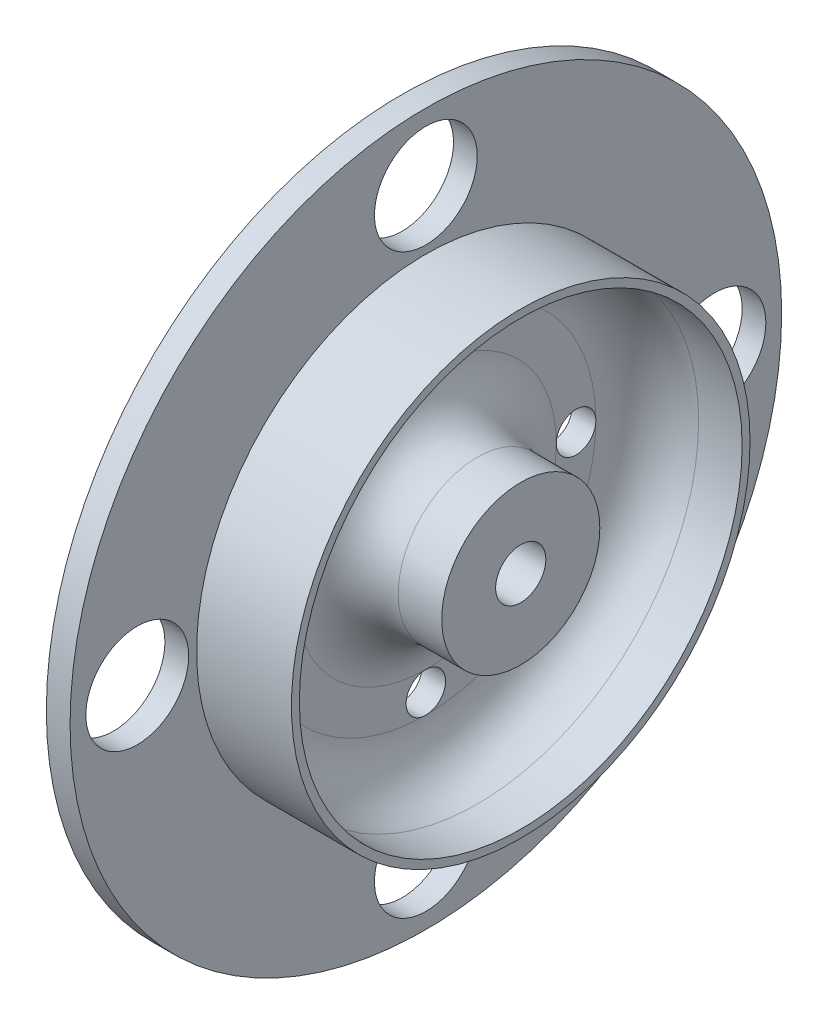
from build123d import *

# Parameters (mm, degrees)
SPROCKET_R                   = 45
ESTRUSIONE_ESTRUSIONE2_DEPTH = 3
SCHIZZO4_R                   = 10
ESTRUSIONE_ESTRUSIONE4_DEPTH = 12
SCHIZZO5_R                   = 29
SCHIZZO5_R_2                 = 28
ESTRUSIONE_ESTRUSIONE5_DEPTH = 12
SCHIZZO6_R                   = 3.175
TAGLIO_ESTRUSIONE1_DEPTH     = 15
RACCORDO1_R                  = 6.5
SCHIZZO7_R                   = 6.5
SCHIZZO7_R_2                 = 2.5
TAGLIO_ESTRUSIONE2_DEPTH     = 4
SCALE1_SCALE                 = 0.888888889


with BuildPart() as part:
    # Sprocket → Estrusione-Estrusione2 (new body)
    with BuildSketch(Plane(origin=(0, 0, 0), x_dir=(0, 0, -1), z_dir=(1, 0, 0))):
        Circle(SPROCKET_R)
    extrude(amount=ESTRUSIONE_ESTRUSIONE2_DEPTH)

    # Schizzo4 → Estrusione-Estrusione4 (add)
    with BuildSketch(Plane(origin=(3, 0, 0), x_dir=(0, 0, -1), z_dir=(1, 0, 0))):
        Circle(SCHIZZO4_R)
    extrude(amount=ESTRUSIONE_ESTRUSIONE4_DEPTH)

    # Schizzo5 → Estrusione-Estrusione5 (add)
    with BuildSketch(Plane(origin=(3, 0, 0), x_dir=(0, 0, -1), z_dir=(1, 0, 0))):
        Circle(SCHIZZO5_R)
        Circle(SCHIZZO5_R_2, mode=Mode.SUBTRACT)
    extrude(amount=ESTRUSIONE_ESTRUSIONE5_DEPTH)

    # Schizzo6 → Taglio-Estrusione1 (cut)
    with BuildSketch(Plane(origin=(15, 0, 0), x_dir=(0, 0, -1), z_dir=(1, 0, 0))):
        Circle(SCHIZZO6_R)
    extrude(amount=-TAGLIO_ESTRUSIONE1_DEPTH, mode=Mode.SUBTRACT)

    # Raccordo1
    raccordo1_edges = [part.edges().sort_by_distance(p)[0] for p in [
        (3, 0, 10),
        (3, 0, 28),
    ]]
    fillet(raccordo1_edges, radius=RACCORDO1_R)

    # Schizzo7 → Taglio-Estrusione2 (cut, through all)
    with BuildSketch(Plane(origin=(3, 0, 0), x_dir=(0, 0, -1), z_dir=(1, 0, 0))):
        with Locations((0, 36.5)):
            Circle(SCHIZZO7_R)
        with Locations((36.5, 0)):
            Circle(SCHIZZO7_R)
        with Locations((0, -36.5)):
            Circle(SCHIZZO7_R)
        with Locations((-36.5, 0)):
            Circle(SCHIZZO7_R)
        with Locations((0, 19)):
            Circle(SCHIZZO7_R_2)
        with Locations((19, 0)):
            Circle(SCHIZZO7_R_2)
        with Locations((0, -19)):
            Circle(SCHIZZO7_R_2)
        with Locations((-19, 0)):
            Circle(SCHIZZO7_R_2)
    extrude(amount=-TAGLIO_ESTRUSIONE2_DEPTH, mode=Mode.SUBTRACT)


with BuildPart() as part_1:
    # Scale1: scaled about (3.427617089, 0, 0)
    add(part.part.scale(SCALE1_SCALE).moved(Location((0.380846343, 0, 0))))


solid = part_1.part
